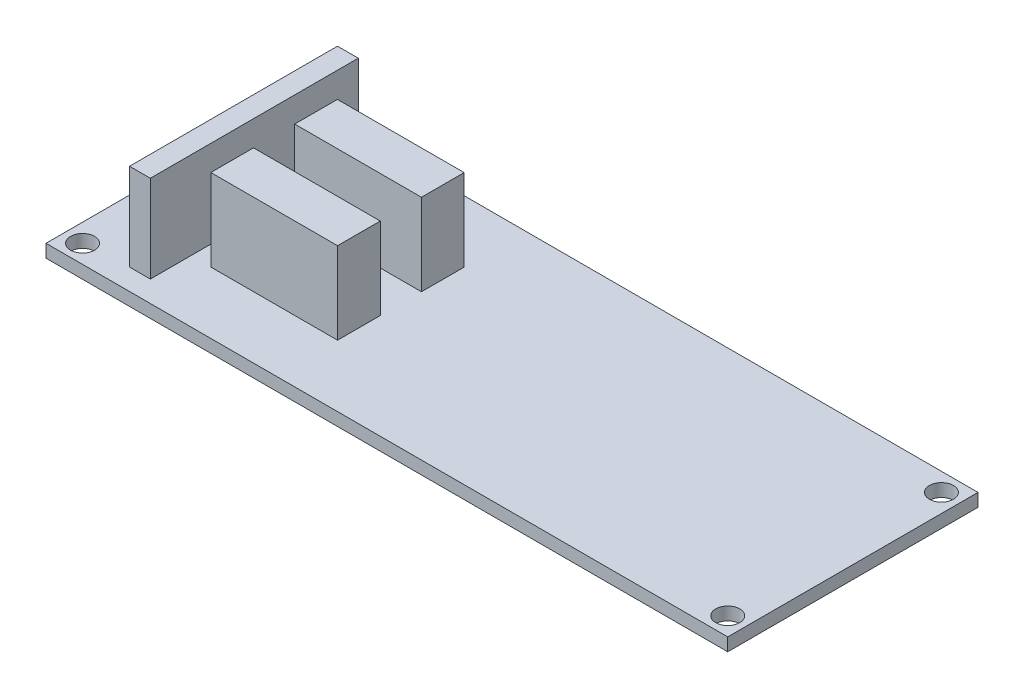
from build123d import *

# Parameters (mm, degrees)
SKETCH1_W                  = 83.2739
SKETCH1_H                  = 30.5689
PROTON_PCB_DEPTH           = 1.58115
SKETCH2_W                  = 15.481187868
SKETCH2_H                  = 5.216136306
JST_6_PIN_CONNECTORS_DEPTH = 10
SKETCH3_W                  = 2.54
SKETCH3_H                  = 25.4
BOSS_EXTRUDE1_DEPTH        = 10.668
SKETCH4_R                  = 1.4652625
CUT_EXTRUDE1_DEPTH         = 1.58115
SKETCH5_W                  = 4.572
SKETCH5_H                  = 3.556
BOSS_EXTRUDE2_DEPTH        = 1.778
SKETCH6_W                  = 17.78
SKETCH6_H                  = 6.858
BOSS_EXTRUDE3_DEPTH        = 2.794


with BuildPart() as part:
    # Sketch1 → Proton PCB (new body)
    with BuildSketch(Plane(origin=(0, 0, 0), x_dir=(1, 0, 0), z_dir=(0, 1, 0))):
        Rectangle(SKETCH1_W, SKETCH1_H)
    extrude(amount=PROTON_PCB_DEPTH)

    # Sketch2 → JST 6 pin Connectors (add)
    with BuildSketch(Plane(origin=(0, 1.58115, 0), x_dir=(1, 0, 0), z_dir=(0, 1, 0))):
        with Locations((-21.31695, 5.12445)):
            Rectangle(SKETCH2_W, SKETCH2_H)
        with Locations((-21.31695, -5.12445)):
            Rectangle(SKETCH2_W, SKETCH2_H)
    extrude(amount=JST_6_PIN_CONNECTORS_DEPTH)

    # Sketch3 → Boss-Extrude1 (add)
    with BuildSketch(Plane(origin=(0, 1.58115, 0), x_dir=(1, 0, 0), z_dir=(0, 1, 0))):
        with Locations((-32.74695, 0)):
            Rectangle(SKETCH3_W, SKETCH3_H)
    extrude(amount=BOSS_EXTRUDE1_DEPTH)

    # Sketch4 → Cut-Extrude1 (cut)
    with BuildSketch(Plane(origin=(0, 1.58115, 0), x_dir=(1, 0, 0), z_dir=(0, 1, 0))):
        with Locations((-39.4033375, 13.0508375)):
            Circle(SKETCH4_R)
        with Locations((39.4033375, 13.0508375)):
            Circle(SKETCH4_R)
        with Locations((-39.4033375, -13.0508375)):
            Circle(SKETCH4_R)
        with Locations((39.4033375, -13.0508375)):
            Circle(SKETCH4_R)
    extrude(amount=-CUT_EXTRUDE1_DEPTH, mode=Mode.SUBTRACT)

    # Sketch5 → Boss-Extrude2 (add)
    with BuildSketch(Plane.XZ):
        with Locations((-20.55495, 9.44245)):
            Rectangle(SKETCH5_W, SKETCH5_H)
        with Locations((-25.88895, 9.44245)):
            Rectangle(SKETCH5_W, SKETCH5_H)
        with Locations((-15.22095, 9.44245)):
            Rectangle(SKETCH5_W, SKETCH5_H)
        with Locations((23.60295, -2.83845)):
            Rectangle(SKETCH5_W, SKETCH5_H)
        with Locations((-15.22095, -9.44245)):
            Rectangle(SKETCH5_W, SKETCH5_H)
        with Locations((-20.55495, -9.44245)):
            Rectangle(SKETCH5_W, SKETCH5_H)
        with Locations((-25.88895, -9.44245)):
            Rectangle(SKETCH5_W, SKETCH5_H)
    extrude(amount=BOSS_EXTRUDE2_DEPTH)

    # Sketch6 → Boss-Extrude3 (add)
    with BuildSketch(Plane.XZ):
        with Locations((-2.26695, 6.77545)):
            Rectangle(SKETCH6_W, SKETCH6_H)
    extrude(amount=BOSS_EXTRUDE3_DEPTH)


solid = part.part
